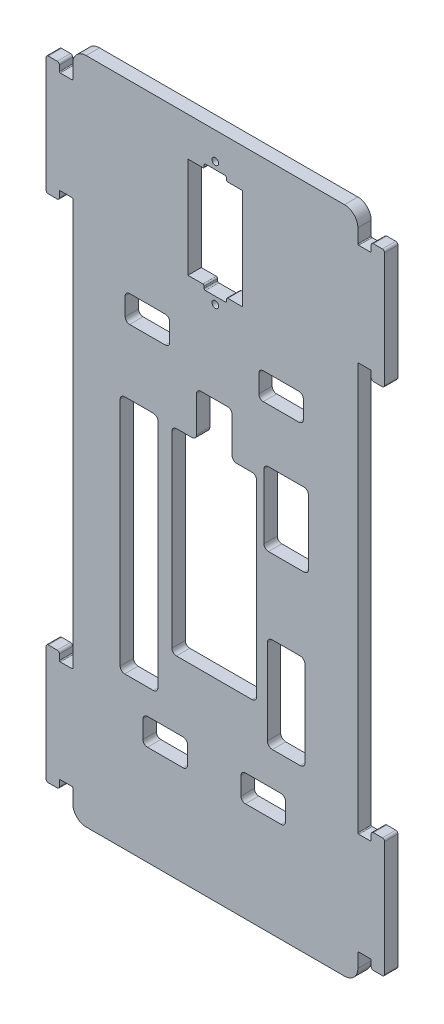
from build123d import *

# Parameters (mm, degrees)
EXTRUDE_1_DEPTH     = 1.5
SKETCH_2_R          = 0.75
SKETCH_2_W          = 12.3
SKETCH_2_H          = 22.6
CUT_EXTRUDE_1_DEPTH = 4
SKETCH_3_W          = 5
SKETCH_3_H          = 1
CUT_EXTRUDE_2_DEPTH = 4
FILLET_1_R          = 0.3
CUT_EXTRUDE_3_DEPTH = 4
CUT_EXTRUDE_4_DEPTH = 4
FILLET_2_R          = 1
CUT_EXTRUDE_5_DEPTH = 4


with BuildPart() as part:
    # 草图1 → 凸台-拉伸1 (new body, symmetric)
    with BuildSketch(Plane.XY):
        with BuildLine():
            Line((32.2, 68.7), (34.8, 68.7))
            ThreePointArc((34.8, 68.7), (34.941421356, 68.758578644), (35, 68.9))
            Line((35, 68.9), (35, 70.15))
            ThreePointArc((35, 70.15), (35.146446609, 70.503553391), (35.5, 70.65))
            Line((35.5, 70.65), (37.5, 70.65))
            ThreePointArc((37.5, 70.65), (37.853553391, 70.503553391), (38, 70.15))
            Line((38, 70.15), (38, 44.35))
            ThreePointArc((38, 44.35), (37.853553391, 43.996446609), (37.5, 43.85))
            Line((37.5, 43.85), (35.5, 43.85))
            ThreePointArc((35.5, 43.85), (35.146446609, 43.996446609), (35, 44.35))
            Line((35, 44.35), (35, 45.6))
            ThreePointArc((35, 45.6), (34.941421356, 45.741421356), (34.8, 45.8))
            Line((34.8, 45.8), (32.2, 45.8))
            ThreePointArc((32.2, 45.8), (32.058578644, 45.741421356), (32, 45.6))
            Line((32, 45.6), (32, -45.6))
            ThreePointArc((32, -45.6), (32.058578644, -45.741421356), (32.2, -45.8))
            Line((32.2, -45.8), (34.8, -45.8))
            ThreePointArc((34.8, -45.8), (34.941421356, -45.741421356), (35, -45.6))
            Line((35, -45.6), (35, -44.35))
            ThreePointArc((35, -44.35), (35.146446609, -43.996446609), (35.5, -43.85))
            Line((35.5, -43.85), (37.5, -43.85))
            ThreePointArc((37.5, -43.85), (37.853553391, -43.996446609), (38, -44.35))
            Line((38, -44.35), (38, -70.15))
            ThreePointArc((38, -70.15), (37.853553391, -70.503553391), (37.5, -70.65))
            Line((37.5, -70.65), (35.5, -70.65))
            ThreePointArc((35.5, -70.65), (35.146446609, -70.503553391), (35, -70.15))
            Line((35, -70.15), (35, -68.9))
            ThreePointArc((35, -68.9), (34.941421356, -68.758578644), (34.8, -68.7))
            Line((34.8, -68.7), (32.2, -68.7))
            ThreePointArc((32.2, -68.7), (32.058578644, -68.758578644), (32, -68.9))
            Line((32, -68.9), (32, -72))
            ThreePointArc((32, -72), (31.121320344, -74.121320344), (29, -75))
            Line((29, -75), (-29, -75))
            ThreePointArc((-29, -75), (-31.121320344, -74.121320344), (-32, -72))
            Line((-32, -72), (-32, -68.9))
            ThreePointArc((-32, -68.9), (-32.058578644, -68.758578644), (-32.2, -68.7))
            Line((-32.2, -68.7), (-34.8, -68.7))
            ThreePointArc((-34.8, -68.7), (-34.941421356, -68.758578644), (-35, -68.9))
            Line((-35, -68.9), (-35, -70.15))
            ThreePointArc((-35, -70.15), (-35.146446609, -70.503553391), (-35.5, -70.65))
            Line((-35.5, -70.65), (-37.5, -70.65))
            ThreePointArc((-37.5, -70.65), (-37.853553391, -70.503553391), (-38, -70.15))
            Line((-38, -70.15), (-38, -44.35))
            ThreePointArc((-38, -44.35), (-37.853553391, -43.996446609), (-37.5, -43.85))
            Line((-37.5, -43.85), (-35.5, -43.85))
            ThreePointArc((-35.5, -43.85), (-35.146446609, -43.996446609), (-35, -44.35))
            Line((-35, -44.35), (-35, -45.6))
            ThreePointArc((-35, -45.6), (-34.941421356, -45.741421356), (-34.8, -45.8))
            Line((-34.8, -45.8), (-32.2, -45.8))
            ThreePointArc((-32.2, -45.8), (-32.058578644, -45.741421356), (-32, -45.6))
            Line((-32, -45.6), (-32, 45.6))
            ThreePointArc((-32, 45.6), (-32.058578644, 45.741421356), (-32.2, 45.8))
            Line((-32.2, 45.8), (-34.8, 45.8))
            ThreePointArc((-34.8, 45.8), (-34.941421356, 45.741421356), (-35, 45.6))
            Line((-35, 45.6), (-35, 44.35))
            ThreePointArc((-35, 44.35), (-35.146446609, 43.996446609), (-35.5, 43.85))
            Line((-35.5, 43.85), (-37.5, 43.85))
            ThreePointArc((-37.5, 43.85), (-37.853553391, 43.996446609), (-38, 44.35))
            Line((-38, 44.35), (-38, 70.15))
            ThreePointArc((-38, 70.15), (-37.853553391, 70.503553391), (-37.5, 70.65))
            Line((-37.5, 70.65), (-35.5, 70.65))
            ThreePointArc((-35.5, 70.65), (-35.146446609, 70.503553391), (-35, 70.15))
            Line((-35, 70.15), (-35, 68.9))
            ThreePointArc((-35, 68.9), (-34.941421356, 68.758578644), (-34.8, 68.7))
            Line((-34.8, 68.7), (-32.2, 68.7))
            ThreePointArc((-32.2, 68.7), (-32.058578644, 68.758578644), (-32, 68.9))
            Line((-32, 68.9), (-32, 72))
            ThreePointArc((-32, 72), (-31.121320344, 74.121320344), (-29, 75))
            Line((-29, 75), (29, 75))
            ThreePointArc((29, 75), (31.121320344, 74.121320344), (32, 72))
            Line((32, 72), (32, 68.9))
            ThreePointArc((32, 68.9), (32.058578644, 68.758578644), (32.2, 68.7))
        make_face()
    extrude(amount=EXTRUDE_1_DEPTH, both=True)

    # 草图2 → 切除-拉伸1 (cut, through all)
    with BuildSketch(Plane.XY.offset(1.5)):
        with Locations((0, 41.1)):
            Circle(SKETCH_2_R)
        with Locations((0, 68.9)):
            Circle(SKETCH_2_R)
        with Locations((0, 55)):
            Rectangle(SKETCH_2_W, SKETCH_2_H)
    extrude(amount=-CUT_EXTRUDE_1_DEPTH, mode=Mode.SUBTRACT)

    # 草图3 → 切除-拉伸2 (cut, through all)
    with BuildSketch(Plane.XY.offset(1.5)):
        with Locations((0, 66.8)):
            Rectangle(SKETCH_3_W, SKETCH_3_H)
        with Locations((0, 43.2)):
            Rectangle(SKETCH_3_W, SKETCH_3_H)
    extrude(amount=-CUT_EXTRUDE_2_DEPTH, mode=Mode.SUBTRACT)

    # 圆角1
    fillet_1_edges = [part.edges().sort_by_distance(p)[0] for p in [
        (2.5, 66.3, 0),
        (-2.5, 66.3, 0),
        (-2.5, 67.3, 0),
        (2.5, 67.3, 0),
        (-2.5, 43.7, 0),
        (2.5, 43.7, 0),
        (2.5, 42.7, 0),
        (-2.5, 42.7, 0),
    ]]
    fillet(fillet_1_edges, radius=FILLET_1_R)

    # 草图4 → 切除-拉伸3 (cut, through all)
    with BuildSketch(Plane.XY.offset(1.5)):
        with BuildLine():
            Line((-20.36, 12.99), (-13.89, 12.99))
            ThreePointArc((-13.89, 12.99), (-13.182893219, 12.697106781), (-12.89, 11.99))
            Line((-12.89, 11.99), (-12.89, -39.9))
            ThreePointArc((-12.89, -39.9), (-13.182893219, -40.607106781), (-13.89, -40.9))
            Line((-13.89, -40.9), (-20.36, -40.9))
            ThreePointArc((-20.36, -40.9), (-21.067106781, -40.607106781), (-21.36, -39.9))
            Line((-21.36, -39.9), (-21.36, 11.99))
            ThreePointArc((-21.36, 11.99), (-21.067106781, 12.697106781), (-20.36, 12.99))
        make_face()
        with BuildLine():
            Line((-8.74, 12.6), (8.26, 12.6))
            ThreePointArc((8.26, 12.6), (8.967106781, 12.307106781), (9.26, 11.6))
            Line((9.26, 11.6), (9.26, -30.6))
            ThreePointArc((9.26, -30.6), (8.967106781, -31.307106781), (8.26, -31.6))
            Line((8.26, -31.6), (-8.74, -31.6))
            ThreePointArc((-8.74, -31.6), (-9.447106781, -31.307106781), (-9.74, -30.6))
            Line((-9.74, -30.6), (-9.74, 11.6))
            ThreePointArc((-9.74, 11.6), (-9.447106781, 12.307106781), (-8.74, 12.6))
        make_face()
        with BuildLine():
            Line((11.91, 15.53), (19.91, 15.53))
            ThreePointArc((19.91, 15.53), (20.617106781, 15.237106781), (20.91, 14.53))
            Line((20.91, 14.53), (20.91, 0.03))
            ThreePointArc((20.91, 0.03), (20.617106781, -0.677106781), (19.91, -0.97))
            Line((19.91, -0.97), (11.91, -0.97))
            ThreePointArc((11.91, -0.97), (11.202893219, -0.677106781), (10.91, 0.03))
            Line((10.91, 0.03), (10.91, 14.53))
            ThreePointArc((10.91, 14.53), (11.202893219, 15.237106781), (11.91, 15.53))
        make_face()
        with BuildLine():
            Line((12.801778644, -17.71), (19.028221356, -17.71))
            ThreePointArc((19.028221356, -17.71), (19.821438642, -18.038561358), (20.15, -18.831778644))
            Line((20.15, -18.831778644), (20.15, -37.908221356))
            ThreePointArc((20.15, -37.908221356), (19.821438642, -38.701438642), (19.028221356, -39.03))
            Line((19.028221356, -39.03), (12.801778644, -39.03))
            ThreePointArc((12.801778644, -39.03), (12.008561358, -38.701438642), (11.68, -37.908221356))
            Line((11.68, -37.908221356), (11.68, -18.831778644))
            ThreePointArc((11.68, -18.831778644), (12.008561358, -18.038561358), (12.801778644, -17.71))
        make_face()
    extrude(amount=-CUT_EXTRUDE_3_DEPTH, mode=Mode.SUBTRACT)

    # 草图5 → 切除-拉伸4 (cut, through all)
    with BuildSketch(Plane.XY.offset(1.5)):
        with BuildLine():
            Line((-3.24, 22.6), (2.76, 22.6))
            ThreePointArc((2.76, 22.6), (3.467106781, 22.307106781), (3.76, 21.6))
            Line((3.76, 21.6), (3.76, 12.6))
            Line((3.76, 12.6), (-4.24, 12.6))
            Line((-4.24, 12.6), (-4.24, 21.6))
            ThreePointArc((-4.24, 21.6), (-3.947106781, 22.307106781), (-3.24, 22.6))
        make_face()
    extrude(amount=-CUT_EXTRUDE_4_DEPTH, mode=Mode.SUBTRACT)

    # 圆角2
    fillet_2_edges = [part.edges().sort_by_distance(p)[0] for p in [
        (3.76, 12.6, 0),
        (-4.24, 12.6, 0),
    ]]
    fillet(fillet_2_edges, radius=FILLET_2_R)

    # 草图6 → 切除-拉伸5 (cut, through all)
    with BuildSketch(Plane.XY.offset(1.5)):
        with BuildLine():
            Line((10.76, 33.6), (18.76, 33.6))
            ThreePointArc((18.76, 33.6), (19.467106781, 33.307106781), (19.76, 32.6))
            Line((19.76, 32.6), (19.76, 28.6))
            ThreePointArc((19.76, 28.6), (19.467106781, 27.892893219), (18.76, 27.6))
            Line((18.76, 27.6), (10.76, 27.6))
            ThreePointArc((10.76, 27.6), (10.052893219, 27.892893219), (9.76, 28.6))
            Line((9.76, 28.6), (9.76, 32.6))
            ThreePointArc((9.76, 32.6), (10.052893219, 33.307106781), (10.76, 33.6))
        make_face()
        with BuildLine():
            Line((6.76, -46.6), (14.76, -46.6))
            ThreePointArc((14.76, -46.6), (15.467106781, -46.892893219), (15.76, -47.6))
            Line((15.76, -47.6), (15.76, -51.6))
            ThreePointArc((15.76, -51.6), (15.467106781, -52.307106781), (14.76, -52.6))
            Line((14.76, -52.6), (6.76, -52.6))
            ThreePointArc((6.76, -52.6), (6.052893219, -52.307106781), (5.76, -51.6))
            Line((5.76, -51.6), (5.76, -47.6))
            ThreePointArc((5.76, -47.6), (6.052893219, -46.892893219), (6.76, -46.6))
        make_face()
        with BuildLine():
            Line((-10.24, 32.6), (-10.24, 28.6))
            ThreePointArc((-10.24, 28.6), (-10.532893219, 27.892893219), (-11.24, 27.6))
            Line((-11.24, 27.6), (-19.24, 27.6))
            ThreePointArc((-19.24, 27.6), (-19.947106781, 27.892893219), (-20.24, 28.6))
            Line((-20.24, 28.6), (-20.24, 32.6))
            ThreePointArc((-20.24, 32.6), (-19.947106781, 33.307106781), (-19.24, 33.6))
            Line((-19.24, 33.6), (-11.24, 33.6))
            ThreePointArc((-11.24, 33.6), (-10.532893219, 33.307106781), (-10.24, 32.6))
        make_face()
        with BuildLine():
            Line((-6.24, -47.6), (-6.24, -51.6))
            ThreePointArc((-6.24, -51.6), (-6.532893219, -52.307106781), (-7.24, -52.6))
            Line((-7.24, -52.6), (-15.24, -52.6))
            ThreePointArc((-15.24, -52.6), (-15.947106781, -52.307106781), (-16.24, -51.6))
            Line((-16.24, -51.6), (-16.24, -47.6))
            ThreePointArc((-16.24, -47.6), (-15.947106781, -46.892893219), (-15.24, -46.6))
            Line((-15.24, -46.6), (-7.24, -46.6))
            ThreePointArc((-7.24, -46.6), (-6.532893219, -46.892893219), (-6.24, -47.6))
        make_face()
    extrude(amount=-CUT_EXTRUDE_5_DEPTH, mode=Mode.SUBTRACT)


solid = part.part
